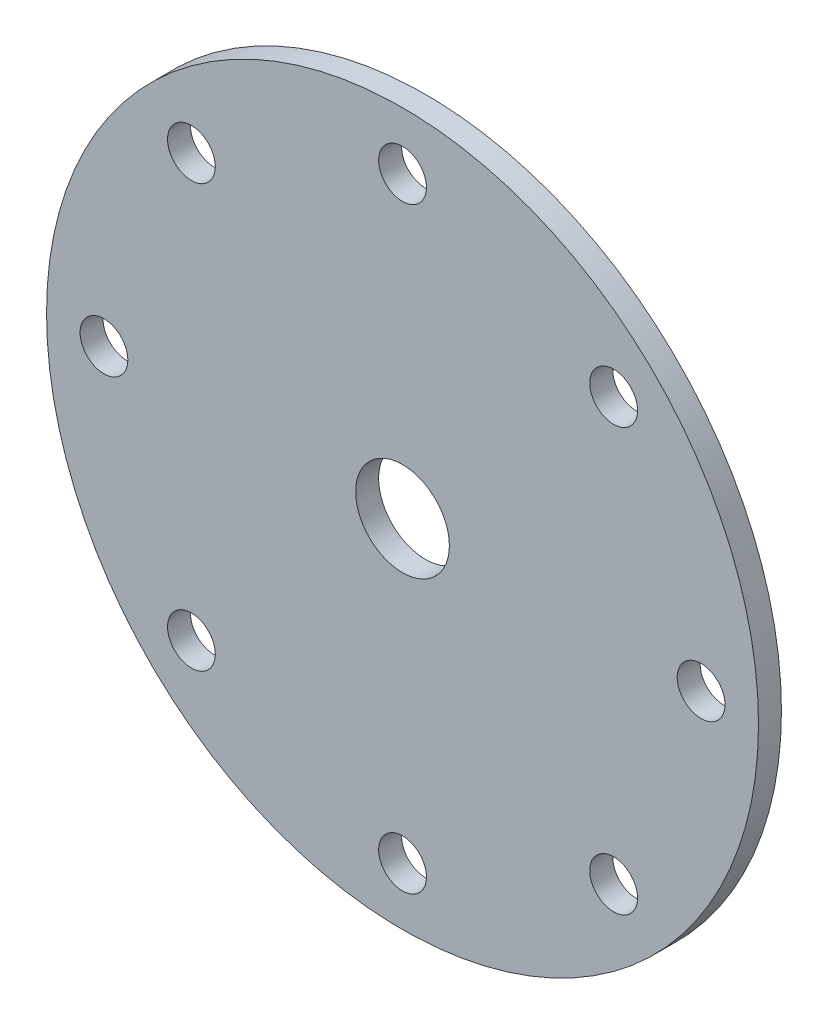
from build123d import *

# Parameters (mm, degrees)
SKETCH1_R        = 98.425
SKETCH1_R_2      = 12.954
SKETCH1_R_3      = 6.604
ROTOR_DISC_DEPTH = 6.35


with BuildPart() as part:
    # Sketch1 → Rotor Disc (new body)
    with BuildSketch(Plane.XY):
        Circle(SKETCH1_R)
        Circle(SKETCH1_R_2, mode=Mode.SUBTRACT)
        with Locations((0, 82.55)):
            Circle(SKETCH1_R_3, mode=Mode.SUBTRACT)
        with Locations((58.371664787, 58.371664787)):
            Circle(SKETCH1_R_3, mode=Mode.SUBTRACT)
        with Locations((82.55, 0)):
            Circle(SKETCH1_R_3, mode=Mode.SUBTRACT)
        with Locations((58.371664787, -58.371664787)):
            Circle(SKETCH1_R_3, mode=Mode.SUBTRACT)
        with Locations((0, -82.55)):
            Circle(SKETCH1_R_3, mode=Mode.SUBTRACT)
        with Locations((-58.371664787, -58.371664787)):
            Circle(SKETCH1_R_3, mode=Mode.SUBTRACT)
        with Locations((-82.55, 0)):
            Circle(SKETCH1_R_3, mode=Mode.SUBTRACT)
        with Locations((-58.371664787, 58.371664787)):
            Circle(SKETCH1_R_3, mode=Mode.SUBTRACT)
    extrude(amount=ROTOR_DISC_DEPTH)


solid = part.part
